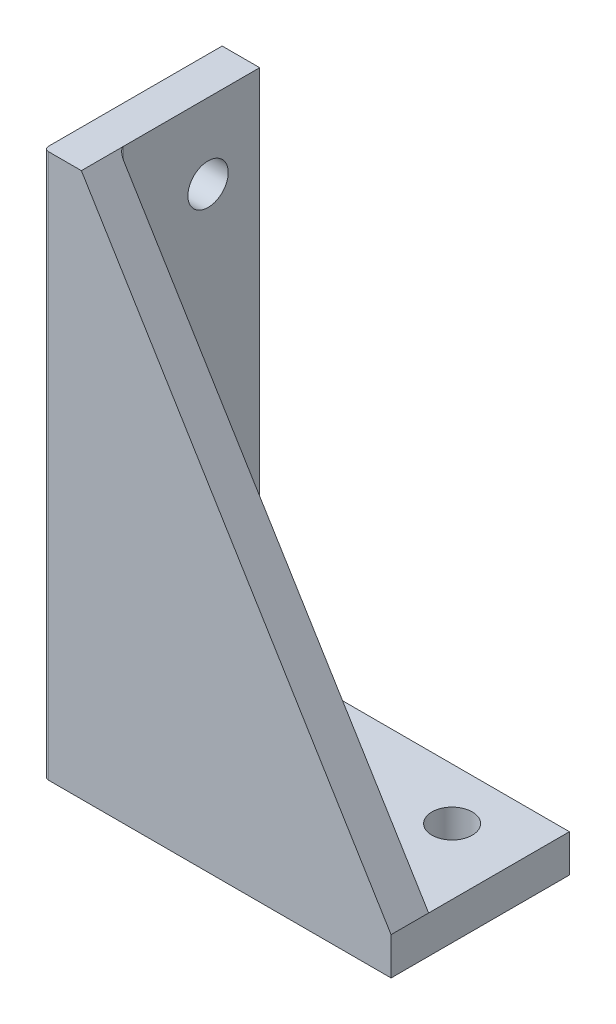
from build123d import *

# Parameters (mm, degrees)
SKETCH1_W            = 37
SKETCH1_H            = 58
BOSS_EXTRUDE1_DEPTH  = 30
SKETCH2_W            = 33
SKETCH2_H            = 13
SKETCH2_W_2          = 4
CUT_EXTRUDE1_DEPTH   = 54
CUT_EXTRUDE2_DEPTH   = 46
M4_CLEARANCE_HOLE1_D = 4.3
M4_CLEARANCE_HOLE2_D = 4.3
SKETCH8_W            = 37
SKETCH8_H            = 13
CUT_EXTRUDE3_DEPTH   = 10
FILLET1_R            = 0.5
BOSS_EXTRUDE2_DEPTH  = 2


with BuildPart() as part:
    # Sketch1 → Boss-Extrude1 (new body)
    with BuildSketch(Plane.XY):
        with Locations((18.5, 29)):
            Rectangle(SKETCH1_W, SKETCH1_H)
    extrude(amount=BOSS_EXTRUDE1_DEPTH)

    # Sketch2 → Cut-Extrude1 (cut)
    with BuildSketch(Plane(origin=(0, 58, 0), x_dir=(1, 0, 0), z_dir=(0, 1, 0))):
        with Locations((20.5, -6.5)):
            Rectangle(SKETCH2_W, SKETCH2_H)
        with Locations((20.5, -23.5)):
            Rectangle(SKETCH2_W, SKETCH2_H)
        with Locations((2, -23.5)):
            Rectangle(SKETCH2_W_2, SKETCH2_H)
    extrude(amount=-CUT_EXTRUDE1_DEPTH, mode=Mode.SUBTRACT)

    # Sketch3 → Cut-Extrude2 (cut)
    with BuildSketch(Plane.XY.offset(13)):
        Polygon((4, 58), (37, 4), (37, 58), align=None)
    extrude(amount=CUT_EXTRUDE2_DEPTH, mode=Mode.SUBTRACT)

    # M4 Clearance Hole1 (through all)
    with Locations(Plane(origin=(4, 0, 0), x_dir=(0, 0, -1), z_dir=(1, 0, 0))):
        with Locations((-3.5, 14), (-3.5, 50)):
            Hole(M4_CLEARANCE_HOLE1_D / 2)

    # M4 Clearance Hole2 (through all)
    with Locations(Plane(origin=(0, 4, 0), x_dir=(1, 0, 0), z_dir=(0, 1, 0))):
        with Locations((12, -3.5), (30, -3.5)):
            Hole(M4_CLEARANCE_HOLE2_D / 2)

    # Sketch8 → Cut-Extrude3 (cut)
    with BuildSketch(Plane(origin=(0, 4, 0), x_dir=(1, 0, 0), z_dir=(0, 1, 0))):
        with Locations((18.5, -23.5)):
            Rectangle(SKETCH8_W, SKETCH8_H)
    extrude(amount=-CUT_EXTRUDE3_DEPTH, mode=Mode.SUBTRACT)

    # Fillet1
    fillet1_edges = [part.edges().sort_by_distance(p)[0] for p in [
        (4, 31, 13),
        (0, 29, 17),
    ]]
    fillet(fillet1_edges, radius=FILLET1_R)

    # Sketch9 → Boss-Extrude2 (add)
    with BuildSketch(Plane(origin=(0, 0, 0), x_dir=(-1, 0, 0), z_dir=(0, 0, -1))):
        Polygon((-4, 58), (0, 58), (0, 0), (-37, 0), (-37, 4), (-4, 4), align=None)
    extrude(amount=BOSS_EXTRUDE2_DEPTH)


solid = part.part
